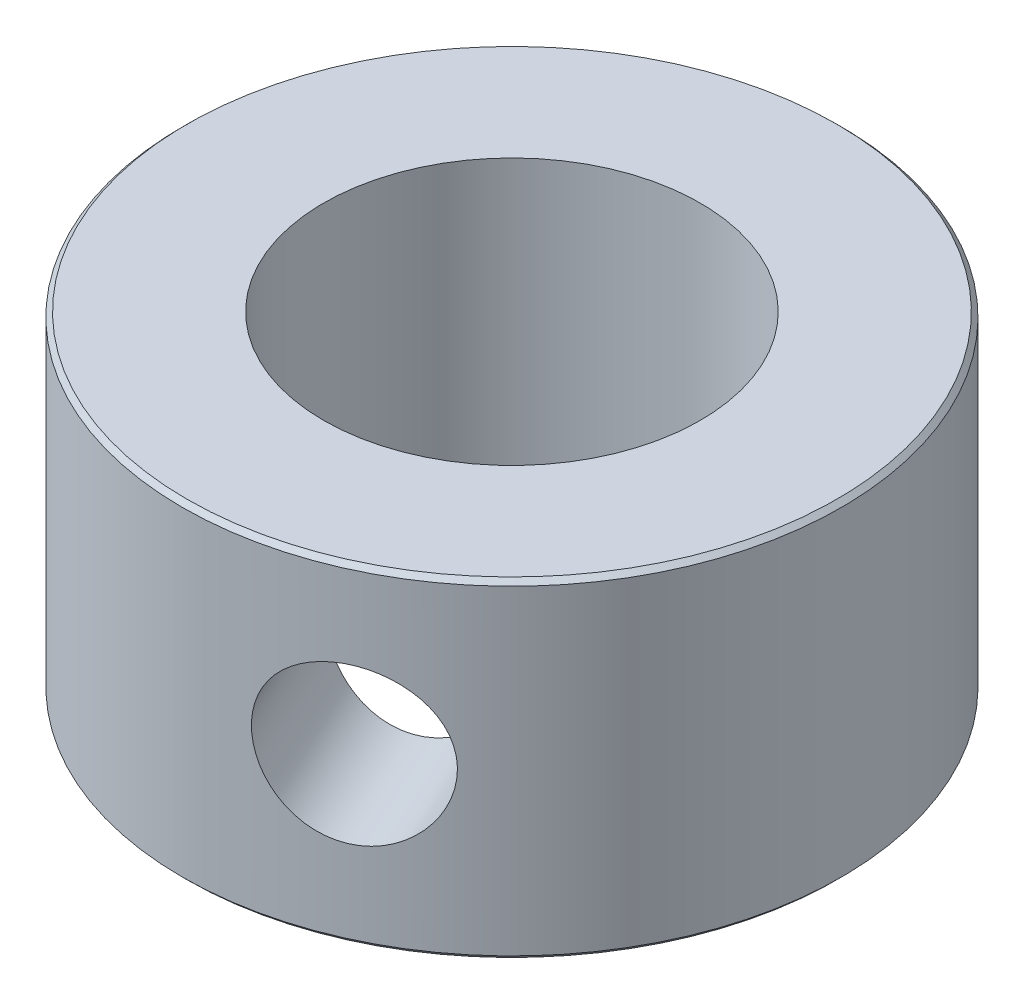
from build123d import *

# Parameters (mm, degrees)
SKETCH2_R                 = 7
SKETCH2_R_2               = 4
BOSS_EXTRUDE1_DEPTH       = 7
M4X0_7_TAPPED_HOLE1_D     = 3.3
M4X0_7_TAPPED_HOLE1_DEPTH = 4
M4X0_7_TAPPED_HOLE1_TIP   = 0.991420021
CHAMFER1_SIZE             = 0.1


with BuildPart() as part:
    # Sketch2 → Boss-Extrude1 (new body)
    with BuildSketch(Plane(origin=(0, 0, 0), x_dir=(1, 0, 0), z_dir=(0, 1, 0))):
        Circle(SKETCH2_R)
        Circle(SKETCH2_R_2, mode=Mode.SUBTRACT)
    extrude(amount=BOSS_EXTRUDE1_DEPTH)

    # M4x0.7 Tapped Hole1
    with Locations(Plane(origin=(2.919589897, 3.5, 6.362074727), x_dir=(0.908867818, 0, -0.417084271), z_dir=(0.417084271, 0, 0.908867818))):
        with Locations((0, 0)):
            Hole(M4X0_7_TAPPED_HOLE1_D / 2, depth=M4X0_7_TAPPED_HOLE1_DEPTH)
            with Locations((0, 0, -(M4X0_7_TAPPED_HOLE1_DEPTH + M4X0_7_TAPPED_HOLE1_TIP / 2))):  # 118° drill point
                Cone(0, M4X0_7_TAPPED_HOLE1_D / 2, M4X0_7_TAPPED_HOLE1_TIP, mode=Mode.SUBTRACT)

    # Chamfer1
    chamfer1_edges = [part.edges().sort_by_distance(p)[0] for p in [
        (-7, 0, 0),
        (-7, 7, 0),
    ]]
    chamfer(chamfer1_edges, length=CHAMFER1_SIZE)


solid = part.part
